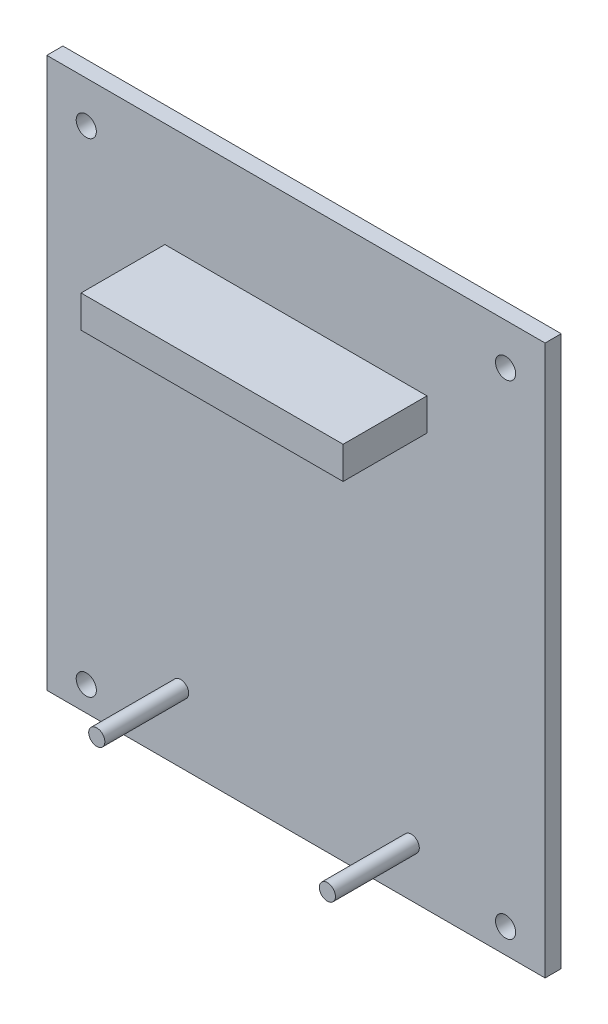
from build123d import *

# Parameters (mm, degrees)
SKETCH1_W           = 78.486
SKETCH1_H           = 86.614
SKETCH1_R           = 1.5875
BOSS_EXTRUDE1_DEPTH = 2.54
SKETCH2_R           = 1.27
SKETCH2_W           = 41.275
SKETCH2_H           = 5.08
BOSS_EXTRUDE2_DEPTH = 13.208


with BuildPart() as part:
    # Sketch1 → Boss-Extrude1 (new body)
    with BuildSketch(Plane.XY):
        with Locations((39.243, 43.307)):
            Rectangle(SKETCH1_W, SKETCH1_H)
        with Locations((6.223, 80.1116)):
            Circle(SKETCH1_R, mode=Mode.SUBTRACT)
        with Locations((72.263, 80.1116)):
            Circle(SKETCH1_R, mode=Mode.SUBTRACT)
        with Locations((72.263, 3.9116)):
            Circle(SKETCH1_R, mode=Mode.SUBTRACT)
        with Locations((6.223, 3.9116)):
            Circle(SKETCH1_R, mode=Mode.SUBTRACT)
    extrude(amount=BOSS_EXTRUDE1_DEPTH)

    # Sketch2 → Boss-Extrude2 (add)
    with BuildSketch(Plane.XY.offset(2.54)):
        with Locations((21.082, 10.7569)):
            Circle(SKETCH2_R)
        with Locations((57.404, 7.8105)):
            Circle(SKETCH2_R)
        with Locations((39.243, 67.564)):
            Rectangle(SKETCH2_W, SKETCH2_H)
    extrude(amount=BOSS_EXTRUDE2_DEPTH)


solid = part.part
